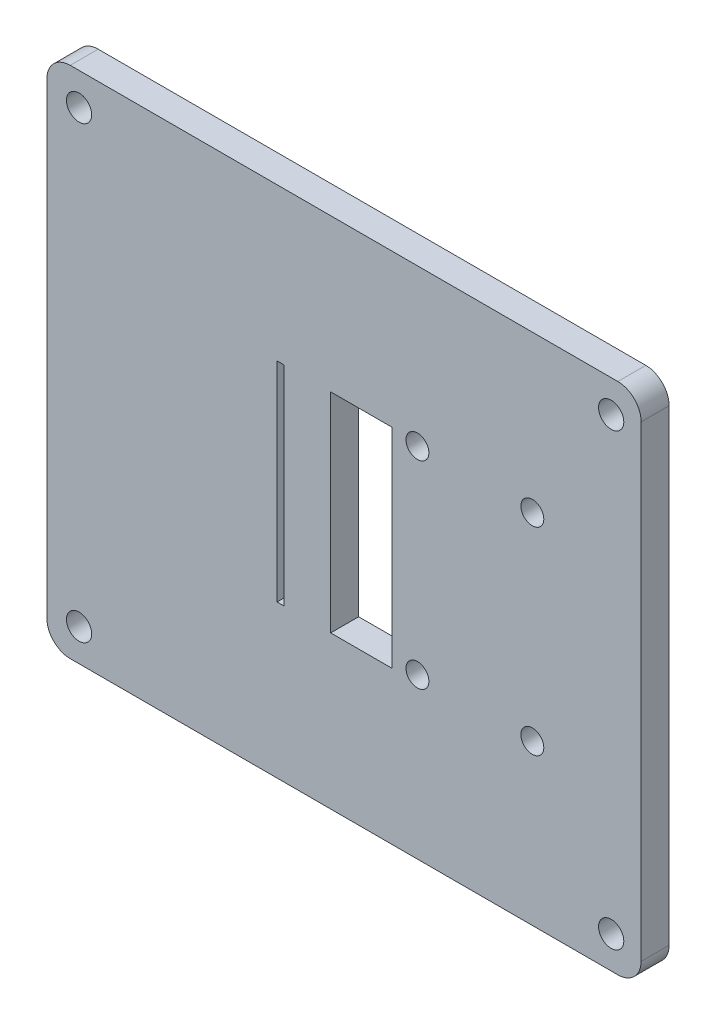
from build123d import *

# Parameters (mm, degrees)
SKETCH1_R           = 1.37499852
BOSS_EXTRUDE1_DEPTH = 3.048
SKETCH2_R           = 1.25
SKETCH2_W           = 6.7
SKETCH2_H           = 22.7542
SKETCH2_W_2         = 0.762
CUT_EXTRUDE1_DEPTH  = 4.048


with BuildPart() as part:
    # Sketch1 → Boss-Extrude1 (new body)
    with BuildSketch(Plane.XY):
        with BuildLine():
            Line((0.41036367, 15.02963974), (60.10036367, 15.02963974))
            ThreePointArc((60.10036367, 15.02963974), (61.896414894, 14.285690964), (62.64036367, 12.48963974))
            Line((62.64036367, 12.48963974), (62.64036367, -38.4396361))
            ThreePointArc((62.64036367, -38.4396361), (61.896414894, -40.235687324), (60.10036367, -40.9796361))
            Line((60.10036367, -40.9796361), (0.41036367, -40.9796361))
            ThreePointArc((0.41036367, -40.9796361), (-1.385687554, -40.235687324), (-2.12963633, -38.4396361))
            Line((-2.12963633, -38.4396361), (-2.12963633, 12.48963974))
            ThreePointArc((-2.12963633, 12.48963974), (-1.385687554, 14.285690964), (0.41036367, 15.02963974))
        make_face()
        with Locations((1.37500106, 11.52500108)):
            Circle(SKETCH1_R, mode=Mode.SUBTRACT)
        with Locations((59.3750019, 11.52500108)):
            Circle(SKETCH1_R, mode=Mode.SUBTRACT)
        with Locations((59.3750019, -37.47499998)):
            Circle(SKETCH1_R, mode=Mode.SUBTRACT)
        with Locations((1.37500106, -37.47499998)):
            Circle(SKETCH1_R, mode=Mode.SUBTRACT)
    extrude(amount=-BOSS_EXTRUDE1_DEPTH)

    # Sketch2 → Cut-Extrude1 (cut, through all)
    with BuildSketch(Plane.XY):
        with Locations((38.25636367, -2.00169818)):
            Circle(SKETCH2_R)
        with Locations((50.77996367, -2.00169818)):
            Circle(SKETCH2_R)
        with Locations((50.77996367, -23.57459818)):
            Circle(SKETCH2_R)
        with Locations((38.25636367, -23.57459818)):
            Circle(SKETCH2_R)
        with Locations((32.15146367, -12.97499818)):
            Rectangle(SKETCH2_W, SKETCH2_H)
        with Locations((23.34046367, -12.97499818)):
            Rectangle(SKETCH2_W_2, SKETCH2_H)
    extrude(amount=-CUT_EXTRUDE1_DEPTH, mode=Mode.SUBTRACT)


solid = part.part
